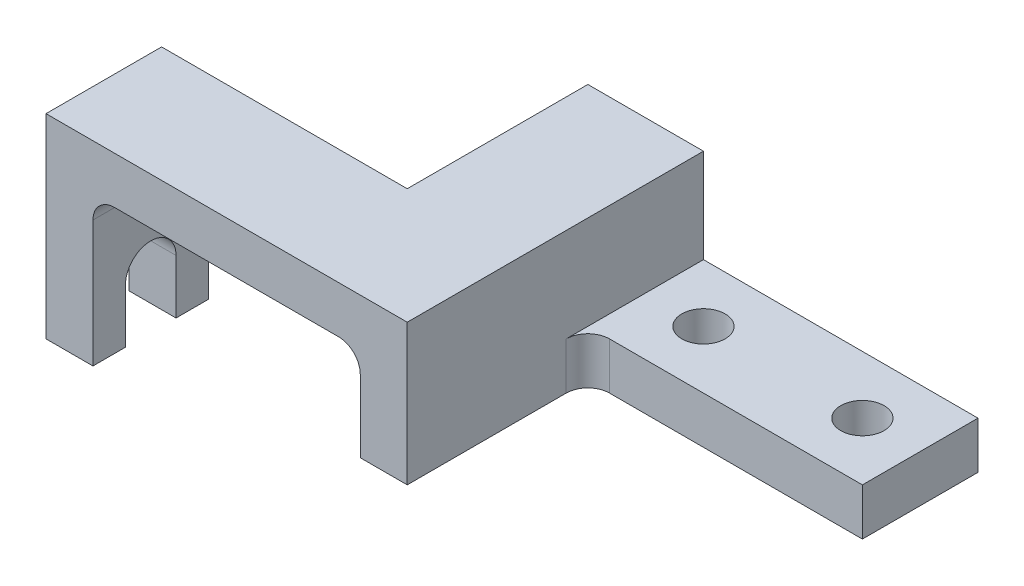
from build123d import *

# Parameters (mm, degrees)
SKETCH1_W                      = 76
SKETCH1_H                      = 32
BOSS_EXTRUDE1_DEPTH            = 13
SKETCH2_R                      = 6
CUT_EXTRUDE1_DEPTH             = 1
CUT_EXTRUDE1_DEPTH_BACK        = 14
SKETCH3_W                      = 82
SKETCH3_H                      = 39
BOSS_EXTRUDE2_DEPTH            = 13
SKETCH4_W                      = 82
SKETCH4_H                      = 13
BOSS_EXTRUDE3_DEPTH            = 87
SKETCH5_W                      = 68
SKETCH5_H                      = 50
CUT_EXTRUDE2_DEPTH             = 1
CUT_EXTRUDE2_DEPTH_BACK        = 40
SKETCH6_W                      = 13
SKETCH6_H                      = 32
BOSS_EXTRUDE4_DEPTH            = 41
FILLET1_R                      = 6
CUT_EXTRUDE3_REACH             = 178
CUT_EXTRUDE3_DIRECTION_2_DEPTH = 1


with BuildPart() as part:
    # Sketch1 → Boss-Extrude1 (new body)
    with BuildSketch(Plane(origin=(0, 0, 0), x_dir=(1, 0, 0), z_dir=(0, 1, 0))):
        Rectangle(SKETCH1_W, SKETCH1_H)
    extrude(amount=BOSS_EXTRUDE1_DEPTH)

    # Sketch2 → Cut-Extrude1 (cut, two sides)
    with BuildSketch(Plane(origin=(0, 13, 0), x_dir=(1, 0, 0), z_dir=(0, 1, 0))) as cut_extrude1_sk:
        with Locations((-22, 0)):
            Circle(SKETCH2_R)
        with Locations((22, 0)):
            Circle(SKETCH2_R)
    extrude(amount=CUT_EXTRUDE1_DEPTH, mode=Mode.SUBTRACT)
    extrude(cut_extrude1_sk.sketch, amount=-CUT_EXTRUDE1_DEPTH_BACK, mode=Mode.SUBTRACT)

    # Sketch3 → Boss-Extrude2 (add)
    with BuildSketch(Plane.ZY.offset(38)):
        with Locations((25, 19.5)):
            Rectangle(SKETCH3_W, SKETCH3_H)
    extrude(amount=BOSS_EXTRUDE2_DEPTH)

    # Sketch4 → Boss-Extrude3 (add)
    with BuildSketch(Plane.ZY.offset(51)):
        with Locations((25, 32.5)):
            Rectangle(SKETCH4_W, SKETCH4_H)
    extrude(amount=BOSS_EXTRUDE3_DEPTH)

    # Sketch5 → Cut-Extrude2 (cut, two sides)
    with BuildSketch(Plane(origin=(0, 39, 0), x_dir=(1, 0, 0), z_dir=(0, 1, 0))) as cut_extrude2_sk:
        with Locations((-104, -9)):
            Rectangle(SKETCH5_W, SKETCH5_H)
    extrude(amount=CUT_EXTRUDE2_DEPTH, mode=Mode.SUBTRACT)
    extrude(cut_extrude2_sk.sketch, amount=-CUT_EXTRUDE2_DEPTH_BACK, mode=Mode.SUBTRACT)

    # Sketch6 → Boss-Extrude4 (add)
    with BuildSketch(Plane.XZ.offset(-26)):
        with Locations((-131.5, 50)):
            Rectangle(SKETCH6_W, SKETCH6_H)
    extrude(amount=BOSS_EXTRUDE4_DEPTH)

    # Fillet1
    fillet1_edges = [part.edges().sort_by_distance(p)[0] for p in [
        (-51, 26, 25),
        (-38, 6.5, 16),
        (-125, 26, 50),
    ]]
    fillet(fillet1_edges, radius=FILLET1_R)

    # Sketch7 → Cut-Extrude3 (cut, up to next)
    with BuildSketch(Plane.ZY.offset(138), mode=Mode.PRIVATE) as cut_extrude3_sk1:
        with BuildLine():
            Line((43, 0), (43, -15))
            Line((43, -15), (57, -15))
            Line((57, -15), (57, 0))
            ThreePointArc((57, 0), (50, 7), (43, 0))
        make_face()
    cut_extrude3_tool1 = extrude(cut_extrude3_sk1.sketch, amount=-CUT_EXTRUDE3_REACH, mode=Mode.PRIVATE) & part.part
    add(cut_extrude3_tool1.solids().sort_by_distance((-138, -4.691563, 50))[0], mode=Mode.SUBTRACT)

    # Sketch7 → Cut-Extrude3 direction 2 (cut)
    with BuildSketch(Plane.ZY.offset(138)):
        with BuildLine():
            Line((43, 0), (43, -15))
            Line((43, -15), (57, -15))
            Line((57, -15), (57, 0))
            ThreePointArc((57, 0), (50, 7), (43, 0))
        make_face()
    extrude(amount=CUT_EXTRUDE3_DIRECTION_2_DEPTH, mode=Mode.SUBTRACT)


solid = part.part
